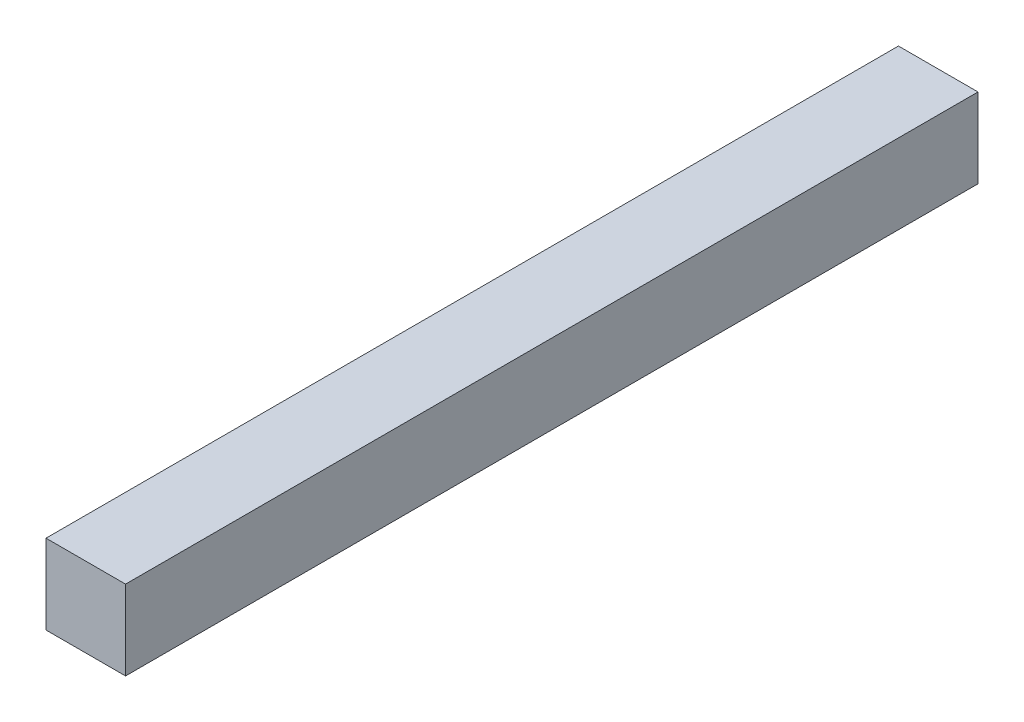
from build123d import *

# Parameters (mm, degrees)
SKETCH1_W           = 2.8
SKETCH1_H           = 2.8
BOSS_EXTRUDE1_DEPTH = 30


with BuildPart() as part:
    # Sketch1 → Boss-Extrude1 (new body)
    with BuildSketch(Plane.XY):
        Rectangle(SKETCH1_W, SKETCH1_H)
    extrude(amount=BOSS_EXTRUDE1_DEPTH)


solid = part.part
